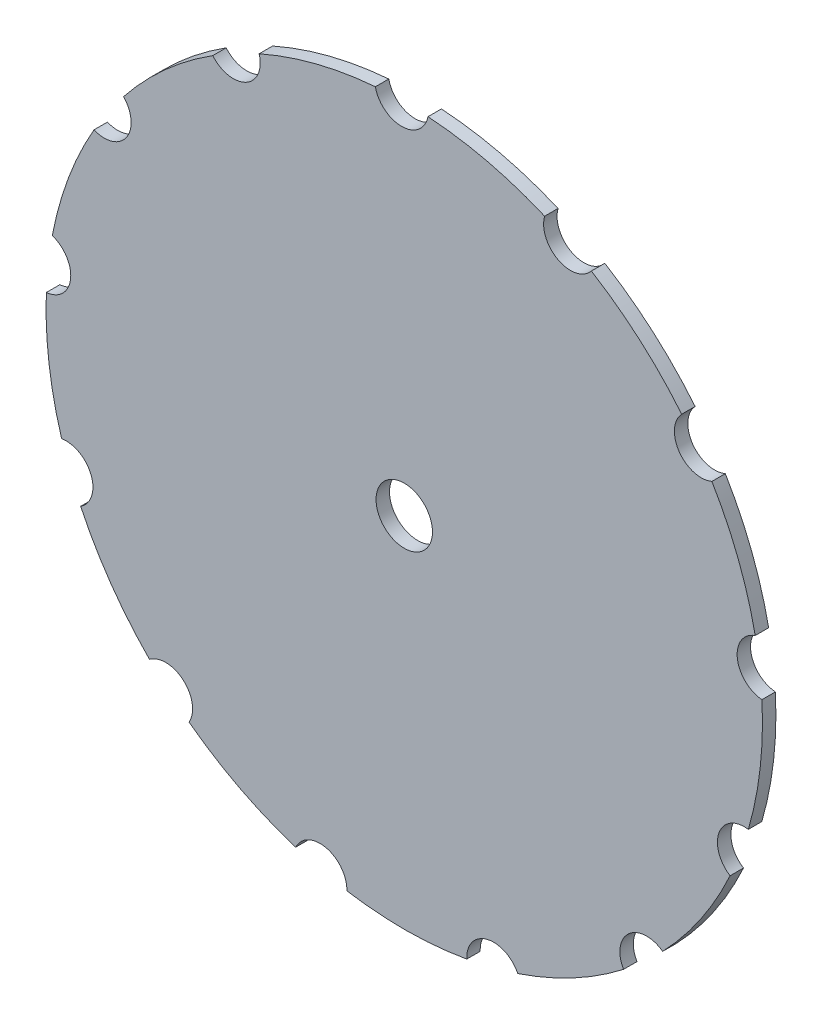
from build123d import *

# Parameters (mm, degrees)
ESQUISSE1_R        = 12.6
BOSS_EXTRU_1_DEPTH = 6


with BuildPart() as part:
    # Esquisse1 → Boss.-Extru.1 (new body)
    with BuildSketch(Plane.XY):
        with BuildLine():
            ThreePointArc((-85.542599785, 135.212660731), (-106.965290191, 118.9891873), (-125.370670455, 99.409229902))
            ThreePointArc((-125.370670455, 99.409229902), (-124.062234057, 84.312289025), (-138.580667025, 79.971236872))
            ThreePointArc((-138.580667025, 79.971236872), (-150.010093296, 55.650443927), (-157.207988245, 29.759845967))
            ThreePointArc((-157.207988245, 29.759845967), (-149.0335271, 17.000229412), (-159.871573528, 6.409366404))
            ThreePointArc((-159.871573528, 6.409366404), (-158.689391845, -20.43714549), (-153.03085049, -46.707160034))
            ThreePointArc((-153.03085049, -46.707160034), (-139.863035133, -54.206377884), (-144.537829197, -68.620812667))
            ThreePointArc((-144.537829197, -68.620812667), (-131.014863137, -91.84283117), (-113.796189109, -112.474118553))
            ThreePointArc((-113.796189109, -112.474118553), (-98.651607349, -112.994957265), (-96.092210067, -127.930790526))
            ThreePointArc((-96.092210067, -127.930790526), (-73.326408184, -142.208431054), (-48.492192196, -152.474611972))
            ThreePointArc((-48.492192196, -152.474611972), (-34.840285202, -145.897753674), (-25.633023647, -157.933366008))
            ThreePointArc((-25.633023647, -157.933366008), (1.160243205, -159.995793181), (27.920781555, -157.545009306))
            ThreePointArc((27.920781555, -157.545009306), (36.952526413, -145.377132974), (50.698379579, -151.755310642))
            ThreePointArc((50.698379579, -151.755310642), (75.381096858, -141.130047249), (97.937440733, -126.523743632))
            ThreePointArc((97.937440733, -126.523743632), (100.279959554, -111.552363094), (115.415395025, -110.811942457))
            ThreePointArc((115.415395025, -110.811942457), (132.333049661, -89.933108294), (145.517812514, -66.517413067))
            ThreePointArc((145.517812514, -66.517413067), (140.634462465, -52.172291181), (153.692134377, -44.482893684))
            ThreePointArc((153.692134377, -44.482893684), (158.969095574, -18.13357804), (159.761807127, 8.727255209))
            ThreePointArc((159.761807127, 8.727255209), (148.771304855, 19.159823897), (156.759857935, 32.036649955))
            ThreePointArc((156.759857935, 32.036649955), (149.187237475, 57.82013641), (137.406297066, 81.972614492))
            ThreePointArc((137.406297066, 81.972614492), (122.826434191, 86.102654221), (123.9157872, 101.216983173))
            ThreePointArc((123.9157872, 101.216983173), (105.228381173, 120.527954416), (83.572660273, 136.439035672))
            ThreePointArc((83.572660273, 136.439035672), (68.743507673, 133.320404113), (62.684102965, 147.209725343))
            ThreePointArc((62.684102965, 147.209725343), (37.162970883, 155.624270585), (10.59353417, 159.648918048))
            ThreePointArc((10.59353417, 159.648918048), (-1.087728004, 149.996056107), (-12.907753834, 159.478493506))
            ThreePointArc((-12.907753834, 159.478493506), (-39.416028174, 155.068941839), (-64.812442944, 146.285157277))
            ThreePointArc((-64.812442944, 146.285157277), (-70.669778304, 132.309419296), (-85.542599785, 135.212660731))
        make_face()
        Circle(ESQUISSE1_R, mode=Mode.SUBTRACT)
    extrude(amount=BOSS_EXTRU_1_DEPTH)


solid = part.part
